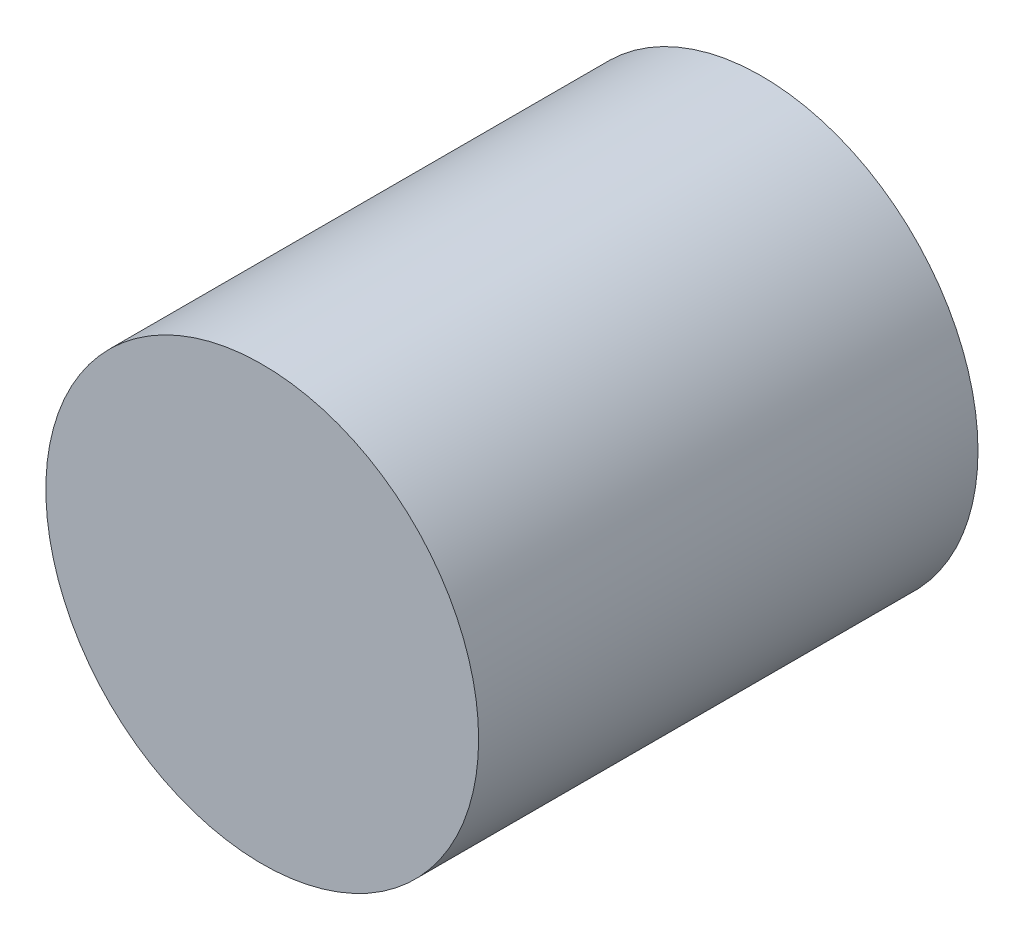
from build123d import *

# Parameters (mm, degrees)
SKETCH1_R           = 3.899999947
BOSS_EXTRUDE1_DEPTH = 9


with BuildPart() as part:
    # Sketch1 → Boss-Extrude1 (new body)
    with BuildSketch(Plane.XY):
        Circle(SKETCH1_R)
    extrude(amount=BOSS_EXTRUDE1_DEPTH)


solid = part.part
